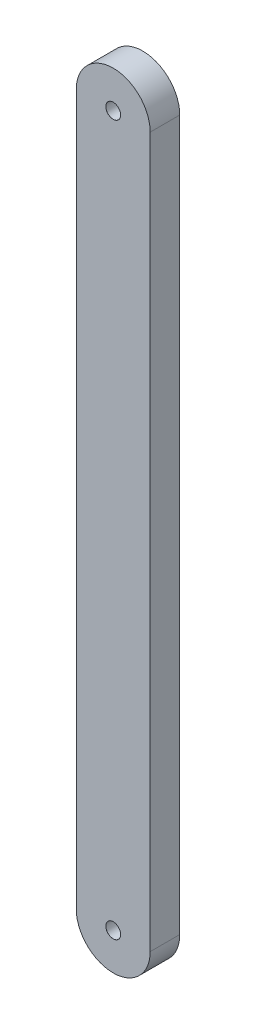
from build123d import *

# Parameters (mm, degrees)
BOSS_EXTRUDE1_DEPTH              = 20
F_10_0MM_DOWEL_HOLE1_D           = 10
F_10_0MM_DOWEL_HOLE1_CSINK_D     = 10.05
F_10_0MM_DOWEL_HOLE1_CSINK_ANGLE = 90
SCALE1_SCALE                     = 0.125


with BuildPart() as part:
    # Sketch2 → Boss-Extrude1 (new body)
    with BuildSketch(Plane.XY):
        with BuildLine():
            Line((-50, -240), (-50, 240))
            ThreePointArc((-50, 240), (-25, 265), (0, 240))
            Line((0, 240), (0, -240))
            ThreePointArc((0, -240), (-25, -265), (-50, -240))
        make_face()
    extrude(amount=BOSS_EXTRUDE1_DEPTH)

    # Ø10.0mm Dowel Hole1 (through all)
    with Locations(Plane.XY.offset(20)):
        with Locations((-25, 240), (-25, -240)):
            CounterSinkHole(F_10_0MM_DOWEL_HOLE1_D / 2, F_10_0MM_DOWEL_HOLE1_CSINK_D / 2, counter_sink_angle=F_10_0MM_DOWEL_HOLE1_CSINK_ANGLE)


with BuildPart() as part_1:
    # Scale1: scaled about (-25, 0, 9.999999619)
    add(part.part.scale(SCALE1_SCALE).moved(Location((-21.875, 0, 8.749999667))))


solid = part_1.part
